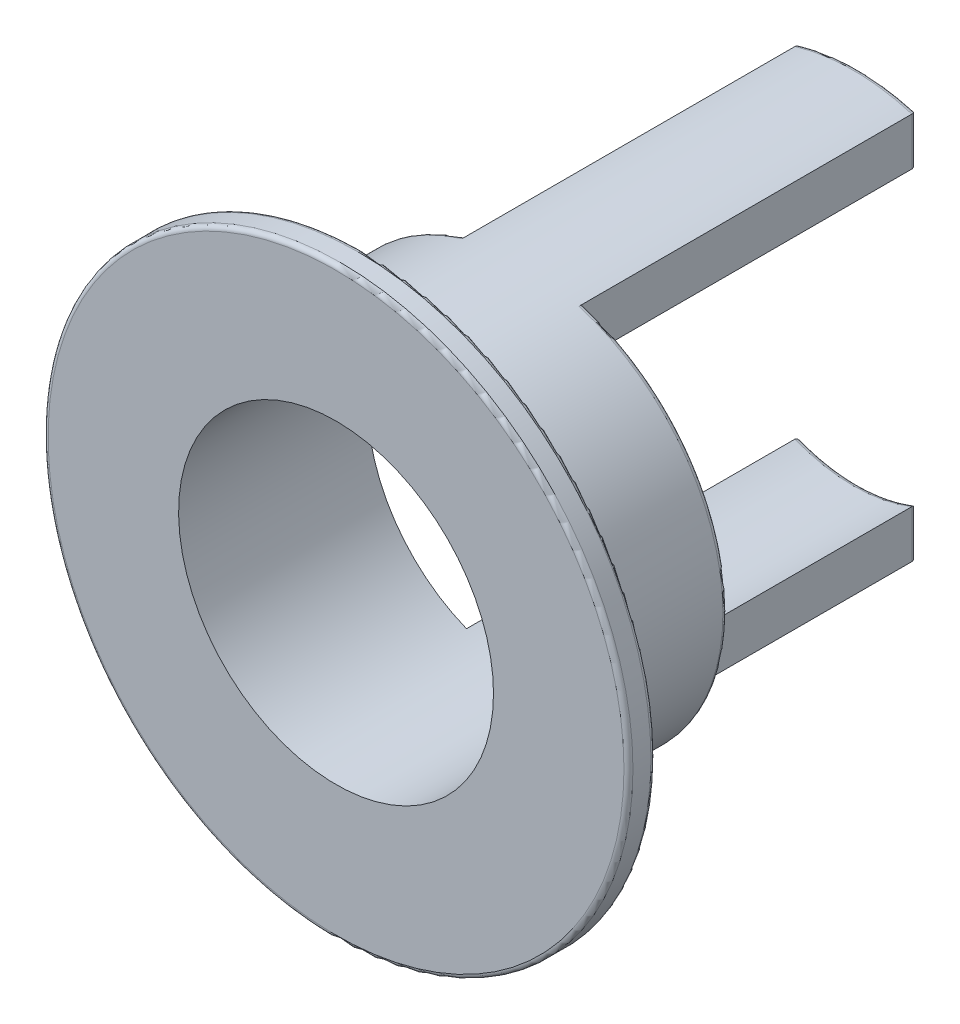
from build123d import *

# Parameters (mm, degrees)
SKETCH_1_R          = 3.25
SKETCH_1_R_2        = 2.25
SKETCH_1_R_3        = 1.75
EXTRUDE_1_DEPTH     = 0.3
SKETCH_1_4_R        = 2.25
SKETCH_1_4_R_2      = 1.75
EXTRUDE_2_DEPTH     = 5.5
CUT_EXTRUDE_1_DEPTH = 3.7
FILLET_1_R          = 0.05


with BuildPart() as part:
    # Sketch 1 → Extrude 1 (new body)
    with BuildSketch(Plane.XY):
        Circle(SKETCH_1_R)
        Circle(SKETCH_1_R_2, mode=Mode.SUBTRACT)
        Circle(SKETCH_1_R_2)
        Circle(SKETCH_1_R_3, mode=Mode.SUBTRACT)
    extrude(amount=EXTRUDE_1_DEPTH)

    # Sketch 1_4 → Extrude 2 (add)
    with BuildSketch(Plane.XY):
        Circle(SKETCH_1_4_R)
        Circle(SKETCH_1_4_R_2, mode=Mode.SUBTRACT)
    extrude(amount=-EXTRUDE_2_DEPTH)

    # Sketch 2 → Cut-Extrude 1 (cut)
    with BuildSketch(Plane(origin=(0, 0, -5.5), x_dir=(-1, 0, 0), z_dir=(0, 0, -1))):
        with BuildLine():
            ThreePointArc((-0.65, 2.154065923), (-2.25, 0), (-0.65, -2.154065923))
            Line((-0.65, -2.154065923), (-0.65, -1.624807681))
            ThreePointArc((-0.65, -1.624807681), (-1.75, 0), (-0.65, 1.624807681))
            Line((-0.65, 1.624807681), (-0.65, 2.154065923))
        make_face()
        with BuildLine():
            Line((0.65, -1.624807681), (0.65, -2.154065923))
            ThreePointArc((0.65, -2.154065923), (1.806239187, -1.341640786), (2.25, 0))
            ThreePointArc((2.25, 0), (1.806239187, 1.341640786), (0.65, 2.154065923))
            Line((0.65, 2.154065923), (0.65, 1.624807681))
            ThreePointArc((0.65, 1.624807681), (1.449137675, 0.981070844), (1.75, 0))
            ThreePointArc((1.75, 0), (1.449137675, -0.981070844), (0.65, -1.624807681))
        make_face()
    extrude(amount=-CUT_EXTRUDE_1_DEPTH, mode=Mode.SUBTRACT)

    # Fillet 1
    fillet_1_edges = [part.edges().sort_by_distance(p)[0] for p in [
        (0, 1.75, -5.5),
        (1.806239187, 1.341640786, -1.8),
        (0.65, -1.889436802, -5.5),
        (0.65, 1.889436802, -5.5),
        (0, -2.25, -5.5),
        (0, -1.75, -5.5),
        (-0.65, -1.889436802, -5.5),
        (-0.65, 1.889436802, -5.5),
        (-2.25, 0, -1.8),
        (-3.25, 0, 0),
        (-3.25, 0, 0.3),
        (0, 2.25, -5.5),
    ]]
    fillet(fillet_1_edges, radius=FILLET_1_R)


solid = part.part
